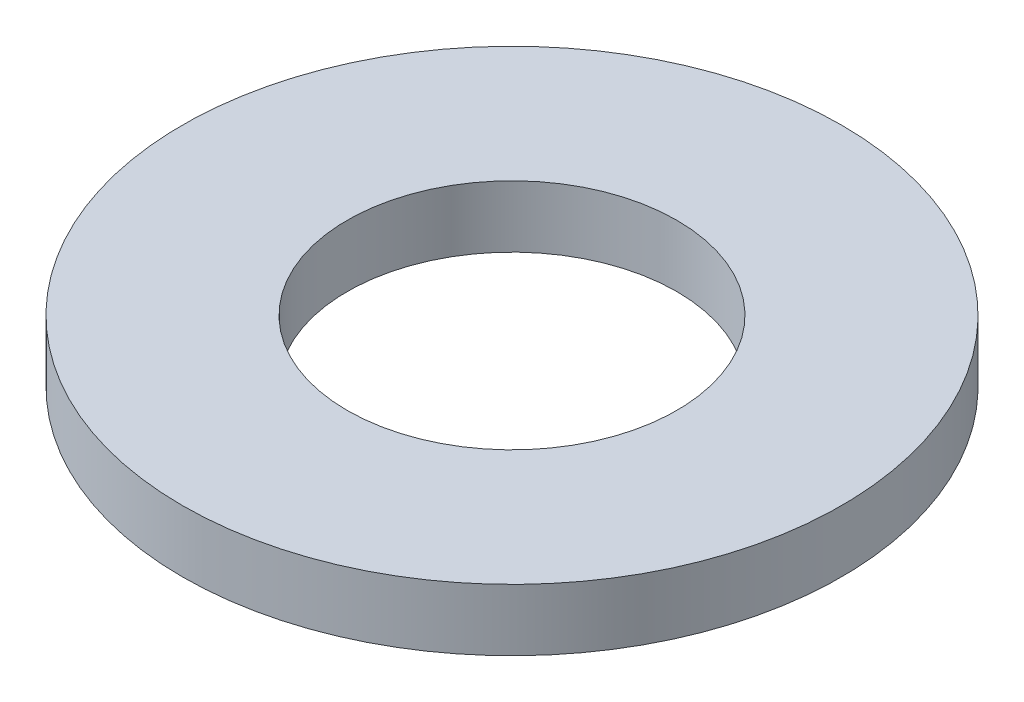
from build123d import *

# Parameters (mm, degrees)
SKETCH_1_R      = 8
SKETCH_1_R_2    = 4
EXTRUDE_1_DEPTH = 1.5


with BuildPart() as part:
    # 草图1 → 凸台-拉伸1 (new body)
    with BuildSketch(Plane(origin=(0, 0, 0), x_dir=(1, 0, 0), z_dir=(0, 1, 0))):
        with Locations((-2.445983916, 0.726151475)):
            Circle(SKETCH_1_R)
        with Locations((-2.445983916, 0.726151475)):
            Circle(SKETCH_1_R_2, mode=Mode.SUBTRACT)
    extrude(amount=EXTRUDE_1_DEPTH)


solid = part.part
